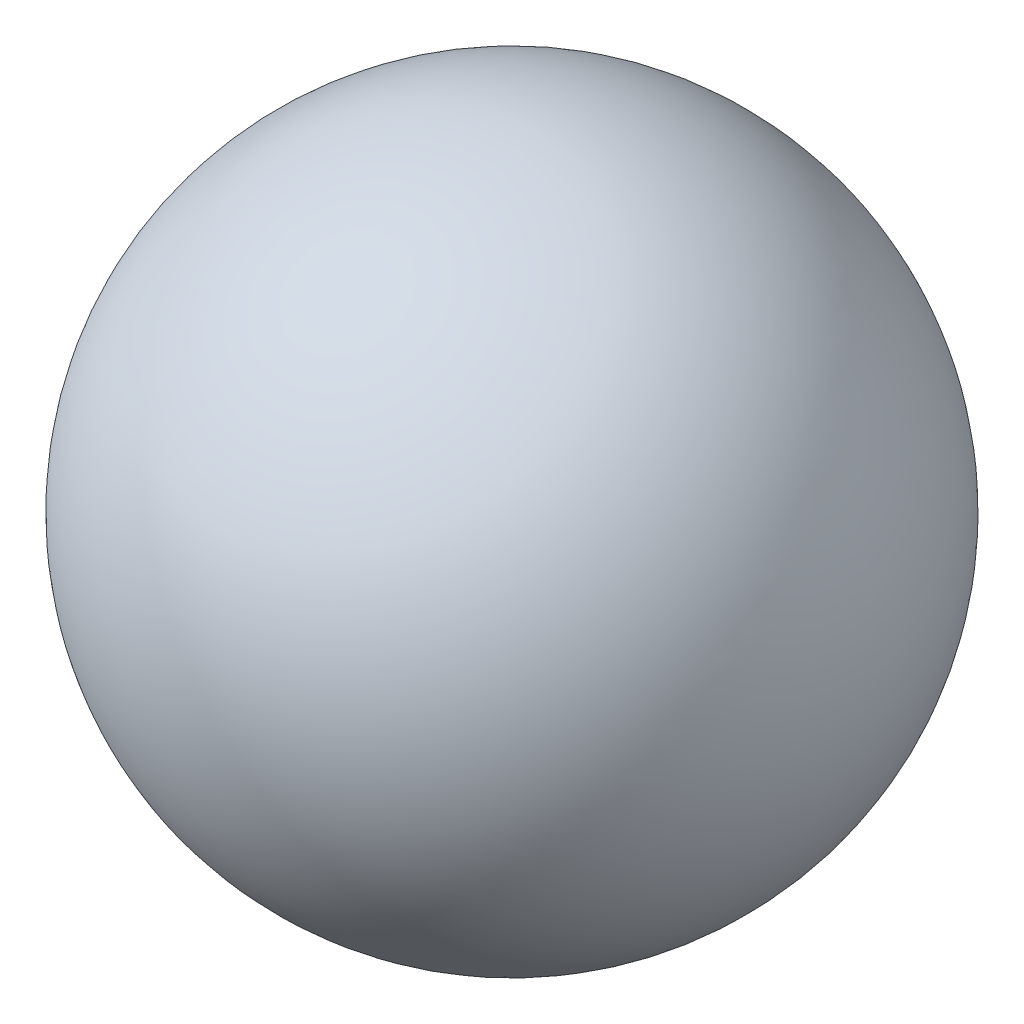
from build123d import *


with BuildPart() as part:
    # 草图1 → 旋转1 (revolve)
    with BuildSketch(Plane(origin=(0, 0, 0), x_dir=(1, 0, 0), z_dir=(0, 1, 0))):
        with BuildLine():
            Line((0, 113), (0, -113))
            ThreePointArc((0, -113), (113, 0), (0, 113))
        make_face()
    revolve(axis=Axis((0, 0, -113), (0, 0, 1)))


solid = part.part
